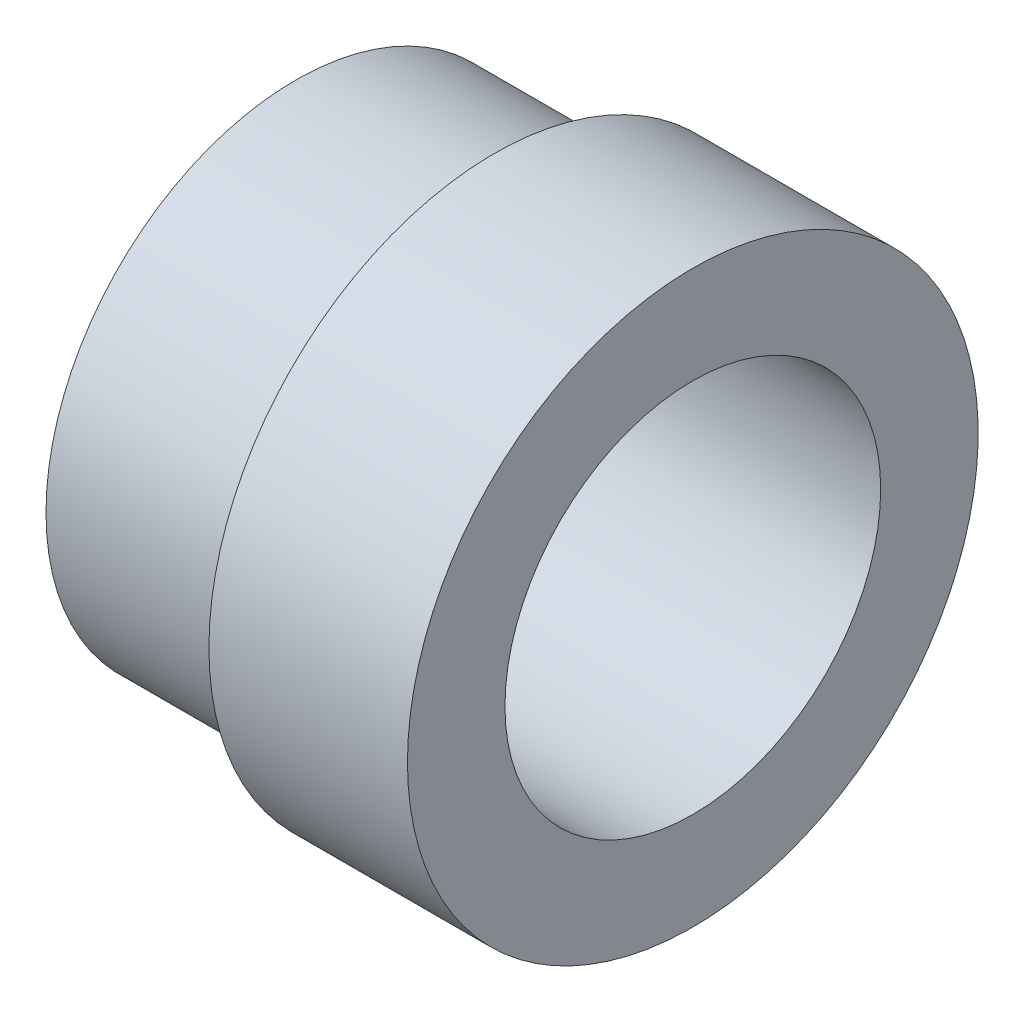
from build123d import *


with BuildPart() as part:
    # Эскиз1 → Повернуть1 (revolve)
    with BuildSketch(Plane.XY):
        Polygon((-98.05, -98), (-89.7, -98), (-89.7, -102.1), (-106.4, -102.1), (-106.4, -99.5), (-98.05, -99.5), align=None)
    revolve(axis=Axis((-106.751905161, -110, 0), (1, 0, 0)))


solid = part.part
